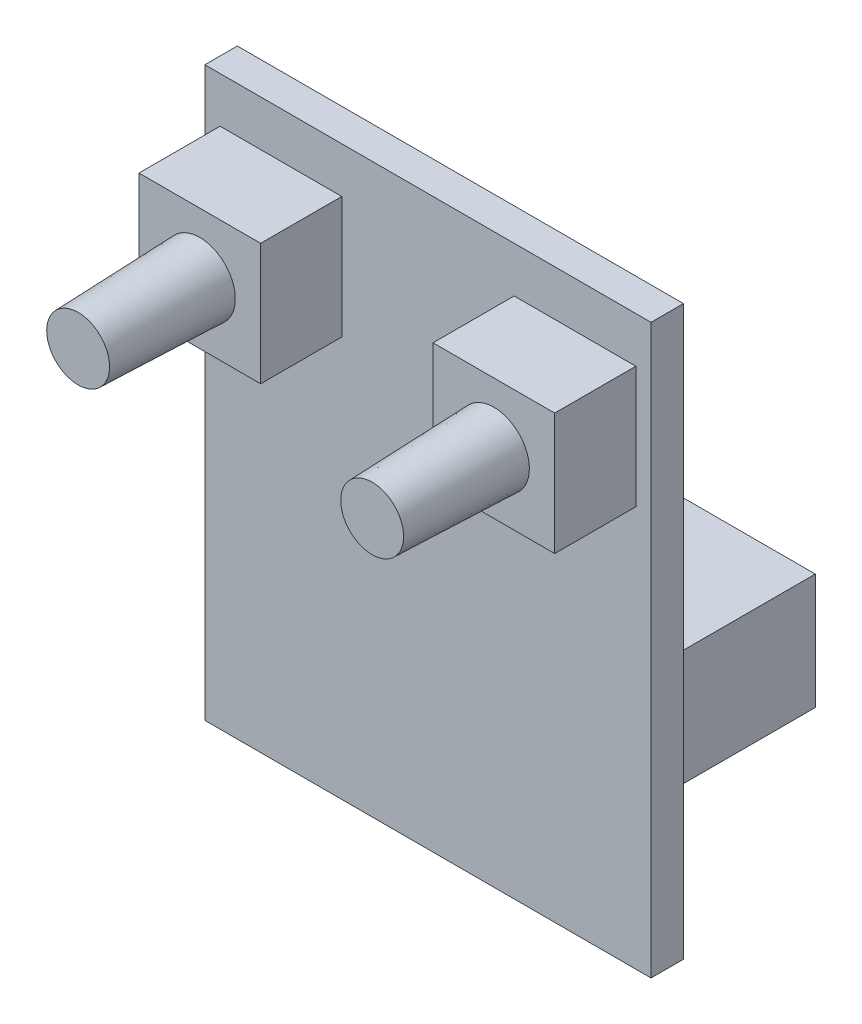
from build123d import *

# Parameters (mm, degrees)
SKETCH1_W           = 22
SKETCH1_H           = 28
BOSS_EXTRUDE1_DEPTH = 1.6
SKETCH2_W           = 6
SKETCH2_H           = 6
BOSS_EXTRUDE2_DEPTH = 4
SKETCH3_W           = 12.5
SKETCH3_H           = 5.7
SKETCH3_W_2         = 7.5
BOSS_EXTRUDE3_DEPTH = 7
SKETCH5_R           = 1.55
SKETCH6_R           = 1.75


with BuildPart() as part:
    # Sketch1 → Boss-Extrude1 (new body)
    with BuildSketch(Plane.XY):
        with Locations((0, 14)):
            Rectangle(SKETCH1_W, SKETCH1_H)
    extrude(amount=BOSS_EXTRUDE1_DEPTH)

    # Sketch2 → Boss-Extrude2 (add)
    with BuildSketch(Plane.XY.offset(1.6)):
        with Locations((7.25, 22.75)):
            Rectangle(SKETCH2_W, SKETCH2_H)
    boss_extrude2 = extrude(amount=BOSS_EXTRUDE2_DEPTH)

    # Sketch3 → Boss-Extrude3 (add)
    with BuildSketch(Plane(origin=(0, 0, 0), x_dir=(-1, 0, 0), z_dir=(0, 0, -1))):
        with Locations((-4.25, 9.85)):
            Rectangle(SKETCH3_W, SKETCH3_H)
        with Locations((6.75, 9.85)):
            Rectangle(SKETCH3_W_2, SKETCH3_H)
    extrude(amount=BOSS_EXTRUDE3_DEPTH)

    # Sketch5 → Loft1 section 0
    with BuildSketch(Plane.XY.offset(11.6)):
        with Locations((7.25, 22.75)):
            Circle(SKETCH5_R)
    # Sketch6 → Loft1 section 1
    with BuildSketch(Plane.XY.offset(5.6)):
        with Locations((7.25, 22.75)):
            Circle(SKETCH6_R)
    loft1 = loft()

    # Mirror1: Boss-Extrude2, Loft1 across plane
    add(boss_extrude2.mirror(Plane(origin=(0, 0, 0), x_dir=(0, 0, 1), z_dir=(1, 0, 0))))
    add(loft1.mirror(Plane(origin=(0, 0, 0), x_dir=(0, 0, 1), z_dir=(1, 0, 0))))


solid = part.part
